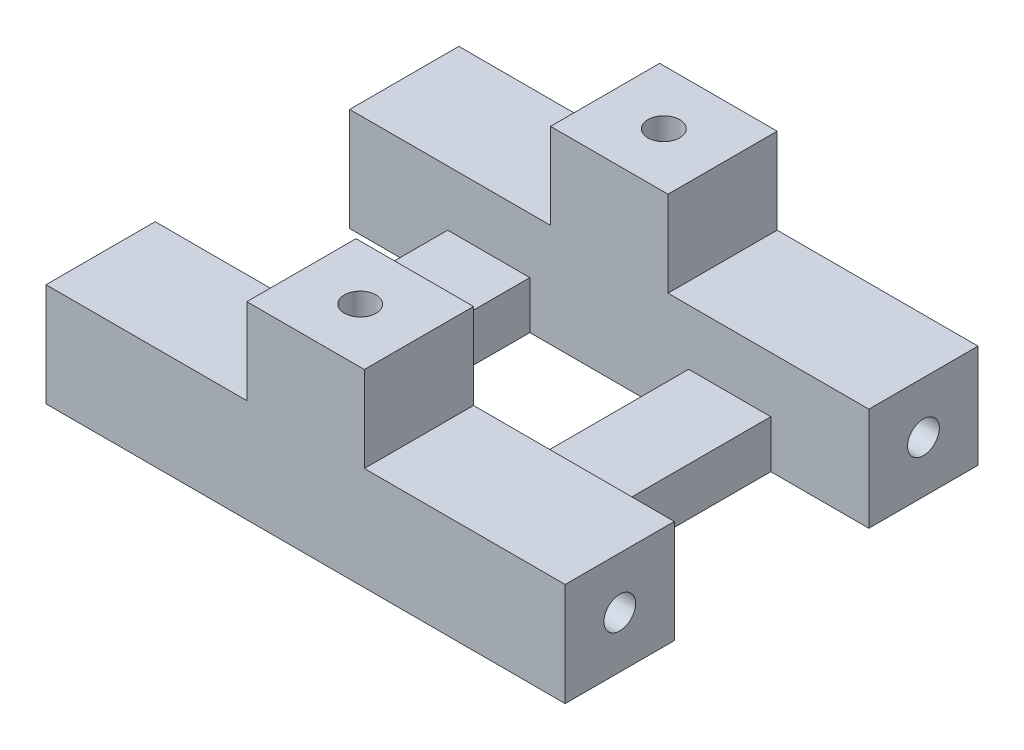
from build123d import *

# Parameters (mm, degrees)
CROQUIS1_W              = 10
CROQUIS1_H              = 12.25
SALIENTE_EXTRUIR1_DEPTH = 6.5
CROQUIS2_W              = 7.4
CROQUIS2_H              = 6.875
CROQUIS2_R              = 1
SALIENTE_EXTRUIR2_DEPTH = 5.4
CROQUIS3_R              = 1
CROQUIS3_W              = 12.25
CROQUIS3_H              = 3.5
CORTAR_EXTRUIR1_DEPTH   = 35.4


with BuildPart() as part:
    # Croquis1 → Saliente-Extruir1 (new body)
    with BuildSketch(Plane(origin=(0, 0, 0), x_dir=(1, 0, 0), z_dir=(0, 1, 0))):
        Polygon((-15.606807411, 13.619327476), (-15.606807411, 6.744327476), (-9.43180722, 6.744327476), (-9.43180722, -5.505672524), (-15.606807411, -5.505672524), (-15.606807411, -12.380672524), (17.093193352, -12.380672524), (17.093193352, -5.505672524), (10.918193161, -5.505672524), (10.918193161, 6.744327476), (17.093193352, 6.744327476), (17.093193352, 13.619327476), align=None)
        with Locations((0.743192971, 0.619327476)):
            Rectangle(CROQUIS1_W, CROQUIS1_H, mode=Mode.SUBTRACT)
    extrude(amount=SALIENTE_EXTRUIR1_DEPTH)

    # Croquis2 → Saliente-Extruir2 (add)
    with BuildSketch(Plane(origin=(0, 6.5, 0), x_dir=(1, 0, 0), z_dir=(0, 1, 0))):
        with Locations((0.743192971, -8.943172524)):
            Rectangle(CROQUIS2_W, CROQUIS2_H)
        with Locations((0.743192971, -8.943172524)):
            Circle(CROQUIS2_R, mode=Mode.SUBTRACT)
        with Locations((0.743192971, 10.181827476)):
            Rectangle(CROQUIS2_W, CROQUIS2_H)
        with Locations((0.743192971, 10.181827476)):
            Circle(CROQUIS2_R, mode=Mode.SUBTRACT)
    extrude(amount=SALIENTE_EXTRUIR2_DEPTH)

    # Croquis3 → Cortar-Extruir1 (cut)
    with BuildSketch(Plane.ZY.offset(15.606807411)):
        with Locations((-10.181827476, 3.25)):
            Circle(CROQUIS3_R)
        with Locations((8.943172524, 3.25)):
            Circle(CROQUIS3_R)
        with Locations((-0.619327476, 4.75)):
            Rectangle(CROQUIS3_W, CROQUIS3_H)
    extrude(amount=-CORTAR_EXTRUIR1_DEPTH, mode=Mode.SUBTRACT)


solid = part.part
